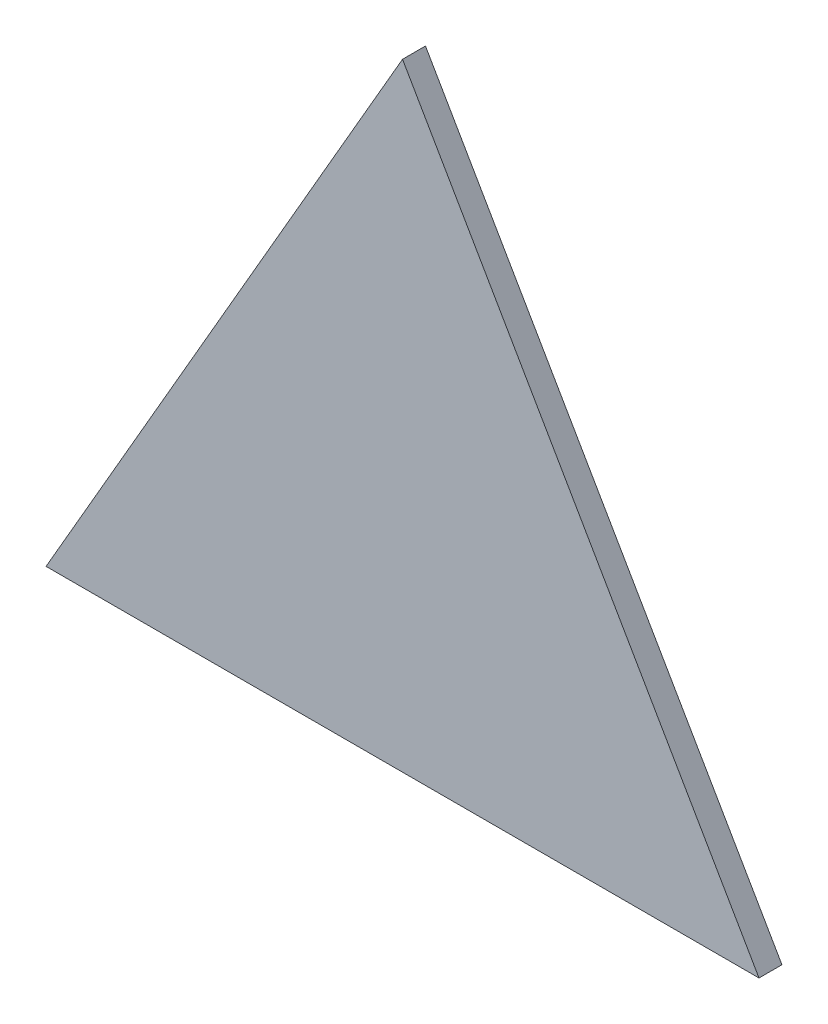
from build123d import *

# Parameters (mm, degrees)
BOSS_EXTRUDE1_DEPTH = 11.90625


with BuildPart() as part:
    # Sketch1 → Boss-Extrude1 (new body)
    with BuildSketch(Plane(origin=(0, 0, 325.23151346), x_dir=(-1, 0, 0), z_dir=(0, 0, -1))):
        Polygon((-279.709293722, 340.36525429), (-94.708555036, 660.795933132), (90.29218365, 340.36525429), align=None)
    extrude(amount=-BOSS_EXTRUDE1_DEPTH)


solid = part.part
